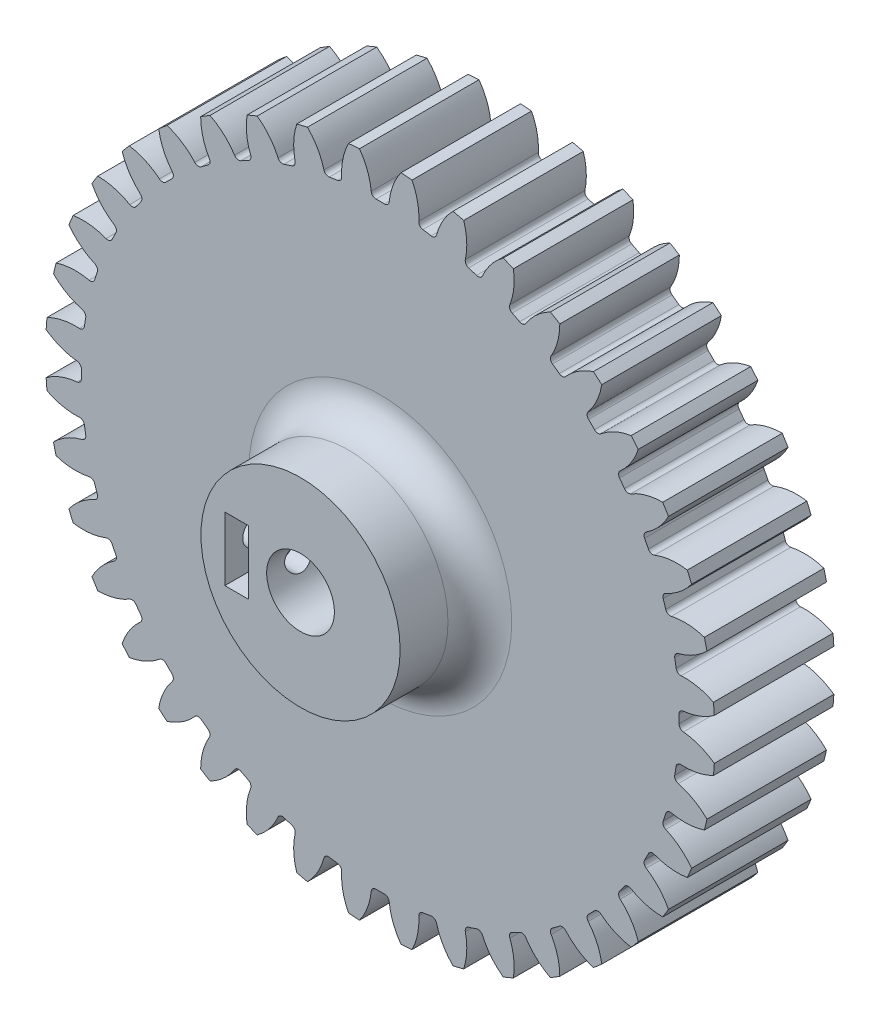
from build123d import *

# Parameters (mm, degrees)
CROQUIS1_R              = 42
SALIENTE_EXTRUIR1_DEPTH = 7.5
CORTAR_EXTRUIR1_DEPTH   = 8.5
REDONDEO1_R             = 0.6
MATRIZC1_COUNT          = 40
REDONDEO1_OF_MATRIZC1_R = 0.6
CORTAR_EXTRUIR2_START   = 7.5
CROQUIS3_R              = 4.25
CORTAR_EXTRUIR2_DEPTH   = 15
SALIENTE_EXTRUIR2_START = 7.5
CROQUIS4_R              = 12.5
CROQUIS4_R_2            = 4.25
SALIENTE_EXTRUIR2_DEPTH = 10
CORTAR_EXTRUIR3_START   = 17.5
CROQUIS5_W              = 3
CROQUIS5_H              = 8
CORTAR_EXTRUIR3_DEPTH   = 8
CORTAR_EXTRUIR4_START   = -12.5
CROQUIS6_R              = 1.75
CORTAR_EXTRUIR4_DEPTH   = 8.627012
REDONDEO2_R             = 4


with BuildPart() as part:
    # Croquis1 → Saliente-Extruir1 (new body, symmetric)
    with BuildSketch(Plane.XY):
        Circle(CROQUIS1_R)
    extrude(amount=SALIENTE_EXTRUIR1_DEPTH, both=True)

    # Croquis2 → Cortar-Extruir1 (cut, symmetric)
    with BuildSketch(Plane.XY):
        with BuildLine():
            ThreePointArc((-1.094689815, 37.484018651), (-1.739742968, 40.395691046), (-3.412974673, 42.864339536))
            ThreePointArc((-3.412974673, 42.864339536), (0, 43), (3.412974673, 42.864339536))
            ThreePointArc((3.412974673, 42.864339536), (1.739742968, 40.395691046), (1.094689815, 37.484018651))
            ThreePointArc((1.094689815, 37.484018651), (0, 37.5), (-1.094689815, 37.484018651))
        make_face()
    cortar_extruir1 = extrude(amount=CORTAR_EXTRUIR1_DEPTH, both=True, mode=Mode.SUBTRACT)

    # Redondeo1
    redondeo1_edges = [part.edges().sort_by_distance(p)[0] for p in [
        (-1.094689815, 37.484018651, 0),
        (1.094689815, 37.484018651, 0),
    ]]
    fillet(redondeo1_edges, radius=REDONDEO1_R)

    # MatrizC1: Cortar-Extruir1 ×40 about axis
    matrizc1_axis = Axis((0, 0, 0), (0, 0, 1))
    for i in range(1, MATRIZC1_COUNT):
        add(cortar_extruir1.rotate(matrizc1_axis, i * 360 / MATRIZC1_COUNT), mode=Mode.SUBTRACT)

    # Redondeo1 of MatrizC1
    redondeo1_of_matrizc1_edges = [part.edges().sort_by_distance(p)[0] for p in [
        (-6.945004772, 36.851280964, 0),
        (-4.782580038, 37.193775396, 0),
        (-12.624310663, 35.311142438, 0),
        (-10.542086898, 35.987697951, 0),
        (-17.992764127, 32.901526394, 0),
        (-16.042012592, 33.895483947, 0),
        (-22.918176024, 29.681765577, 0),
        (-21.146930695, 30.968650635, 0),
        (-27.279266366, 25.731141182, 0),
        (-25.731141182, 27.279266366, 0),
        (-30.968650635, 21.146930695, 0),
        (-29.681765577, 22.918176024, 0),
        (-33.895483947, 16.042012592, 0),
        (-32.901526394, 17.992764127, 0),
        (-35.987697951, 10.542086898, 0),
        (-35.311142438, 12.624310663, 0),
        (-37.193775396, 4.782580038, 0),
        (-36.851280964, 6.945004772, 0),
        (-37.484018651, -1.094689815, 0),
        (-37.484018651, 1.094689815, 0),
        (-36.851280964, -6.945004772, 0),
        (-37.193775396, -4.782580038, 0),
        (-35.311142438, -12.624310663, 0),
        (-35.987697951, -10.542086898, 0),
        (-32.901526394, -17.992764127, 0),
        (-33.895483947, -16.042012592, 0),
        (-29.681765577, -22.918176024, 0),
        (-30.968650635, -21.146930695, 0),
        (-25.731141182, -27.279266366, 0),
        (-27.279266366, -25.731141182, 0),
        (-21.146930695, -30.968650635, 0),
        (-22.918176024, -29.681765577, 0),
        (-16.042012592, -33.895483947, 0),
        (-17.992764127, -32.901526394, 0),
        (-10.542086898, -35.987697951, 0),
        (-12.624310663, -35.311142438, 0),
        (-4.782580038, -37.193775396, 0),
        (-6.945004772, -36.851280964, 0),
        (1.094689815, -37.484018651, 0),
        (-1.094689815, -37.484018651, 0),
        (6.945004772, -36.851280964, 0),
        (4.782580038, -37.193775396, 0),
        (12.624310663, -35.311142438, 0),
        (10.542086898, -35.987697951, 0),
        (17.992764127, -32.901526394, 0),
        (16.042012592, -33.895483947, 0),
        (22.918176024, -29.681765577, 0),
        (21.146930695, -30.968650635, 0),
        (27.279266366, -25.731141182, 0),
        (25.731141182, -27.279266366, 0),
        (30.968650635, -21.146930695, 0),
        (29.681765577, -22.918176024, 0),
        (33.895483947, -16.042012592, 0),
        (32.901526394, -17.992764127, 0),
        (35.987697951, -10.542086898, 0),
        (35.311142438, -12.624310663, 0),
        (37.193775396, -4.782580038, 0),
        (36.851280964, -6.945004772, 0),
        (37.484018651, 1.094689815, 0),
        (37.484018651, -1.094689815, 0),
        (36.851280964, 6.945004772, 0),
        (37.193775396, 4.782580038, 0),
        (35.311142438, 12.624310663, 0),
        (35.987697951, 10.542086898, 0),
        (32.901526394, 17.992764127, 0),
        (33.895483947, 16.042012592, 0),
        (29.681765577, 22.918176024, 0),
        (30.968650635, 21.146930695, 0),
        (25.731141182, 27.279266366, 0),
        (27.279266366, 25.731141182, 0),
        (21.146930695, 30.968650635, 0),
        (22.918176024, 29.681765577, 0),
        (16.042012592, 33.895483947, 0),
        (17.992764127, 32.901526394, 0),
        (10.542086898, 35.987697951, 0),
        (12.624310663, 35.311142438, 0),
        (4.782580038, 37.193775396, 0),
        (6.945004772, 36.851280964, 0),
    ]]
    fillet(redondeo1_of_matrizc1_edges, radius=REDONDEO1_OF_MATRIZC1_R)

    # Croquis3 → Cortar-Extruir2 (cut)
    with BuildSketch(Plane.XY.offset(CORTAR_EXTRUIR2_START)):
        Circle(CROQUIS3_R)
    extrude(amount=-CORTAR_EXTRUIR2_DEPTH, mode=Mode.SUBTRACT)

    # Croquis4 → Saliente-Extruir2 (add)
    with BuildSketch(Plane.XY.offset(SALIENTE_EXTRUIR2_START)):
        Circle(CROQUIS4_R)
        Circle(CROQUIS4_R_2, mode=Mode.SUBTRACT)
    extrude(amount=SALIENTE_EXTRUIR2_DEPTH)

    # Croquis5 → Cortar-Extruir3 (cut)
    with BuildSketch(Plane.XY.offset(CORTAR_EXTRUIR3_START)):
        with Locations((-8, 0)):
            Rectangle(CROQUIS5_W, CROQUIS5_H)
    extrude(amount=-CORTAR_EXTRUIR3_DEPTH, mode=Mode.SUBTRACT)

    # Croquis6 → Cortar-Extruir4 (cut)
    with BuildSketch(Plane(origin=(0, 0, 0), x_dir=(0, 0, -1), z_dir=(1, 0, 0)).offset(CORTAR_EXTRUIR4_START)):
        with Locations((-13.5, 0)):
            Circle(CROQUIS6_R)
    extrude(amount=CORTAR_EXTRUIR4_DEPTH, mode=Mode.SUBTRACT)

    # Redondeo2
    redondeo2_edges = [part.edges().sort_by_distance(p)[0] for p in [
        (-12.5, 0, 7.5),
    ]]
    fillet(redondeo2_edges, radius=REDONDEO2_R)


solid = part.part
